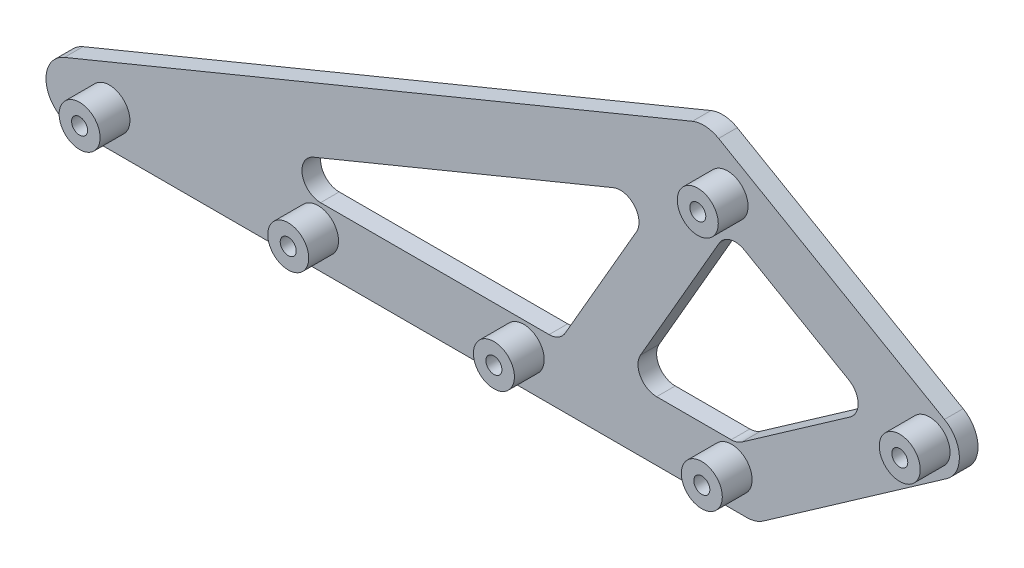
from build123d import *

# Parameters (mm, degrees)
BOSS_EXTRUDE1_DEPTH = 5
BOSS_EXTRUDE2_DEPTH = 5
FILLET1_R           = 5
SKETCH3_R           = 5.5
SKETCH3_R_2         = 2.15
BOSS_EXTRUDE3_DEPTH = 8
SKETCH4_R           = 2.15
CUT_EXTRUDE1_DEPTH  = 6


with BuildPart() as part:
    # Sketch1 → Boss-Extrude1 (new body)
    with BuildSketch(Plane.XY):
        with BuildLine():
            Line((0, 8), (180, 8))
            ThreePointArc((180, 8), (188, 0), (180, -8))
            Line((180, -8), (0, -8))
            ThreePointArc((0, -8), (-8, 0), (0, 8))
        make_face()
        with BuildLine():
            Line((175.411388509, 6.553216354), (224.560511167, 40.967802535))
            ThreePointArc((224.560511167, 40.967802535), (235.702339012, 39.003197672), (233.737734148, 27.861369827))
            Line((233.737734148, 27.861369827), (184.588611491, -6.553216354))
            ThreePointArc((184.588611491, -6.553216354), (173.446783646, -4.588611491), (175.411388509, 6.553216354))
        make_face()
        with BuildLine():
            Line((225.149122657, 27.486382951), (164.527344392, 62.486382951))
            ThreePointArc((164.527344392, 62.486382951), (161.599141162, 73.414586181), (172.527344392, 76.342789411))
            Line((172.527344392, 76.342789411), (233.149122657, 41.342789411))
            ThreePointArc((233.149122657, 41.342789411), (236.077325888, 30.414586181), (225.149122657, 27.486382951))
        make_face()
        with BuildLine():
            Line((-3.04678556, 7.397100632), (165.480558833, 76.811686813))
            ThreePointArc((165.480558833, 76.811686813), (175.924445024, 72.461371741), (171.574129952, 62.017485549))
            Line((171.574129952, 62.017485549), (3.04678556, -7.397100632))
            ThreePointArc((3.04678556, -7.397100632), (-7.397100632, -3.04678556), (-3.04678556, 7.397100632))
        make_face()
    extrude(amount=BOSS_EXTRUDE1_DEPTH)

    # Sketch2 → Boss-Extrude2 (add)
    with BuildSketch(Plane.XY.offset(5)):
        Polygon((147.229345289, 8), (175.147140962, 56.355040542), (167.935409097, 60.518735876), (157.826632887, 56.355040542), (129.908837213, 8), align=None)
    extrude(amount=-BOSS_EXTRUDE2_DEPTH)

    # Fillet1
    fillet1_edges = [part.edges().sort_by_distance(p)[0] for p in [
        (40.428445864, 8, 2.5),
        (177.477609689, 8, 2.5),
        (214.274021971, 33.765125259, 2.5),
        (157.826632887, 56.355040542, 2.5),
        (129.908837213, 8, 2.5),
        (147.229345289, 8, 2.5),
        (175.147140962, 56.355040542, 2.5),
    ]]
    fillet(fillet1_edges, radius=FILLET1_R)

    # Sketch3 → Boss-Extrude3 (add)
    with BuildSketch(Plane.XY.offset(5)):
        with Locations((174.937796577, 64.5)):
            Circle(SKETCH3_R)
        with Locations((174.937796577, 64.5)):
            Circle(SKETCH3_R_2, mode=Mode.SUBTRACT)
        with Locations((229.149122657, 34.414586181)):
            Circle(SKETCH3_R)
        with Locations((229.149122657, 34.414586181)):
            Circle(SKETCH3_R_2, mode=Mode.SUBTRACT)
        with Locations((176.018340463, 1.5)):
            Circle(SKETCH3_R)
        with Locations((176.018340463, 1.5)):
            Circle(SKETCH3_R_2, mode=Mode.SUBTRACT)
        with Locations((120.218340463, 1.5)):
            Circle(SKETCH3_R)
        with Locations((120.218340463, 1.5)):
            Circle(SKETCH3_R_2, mode=Mode.SUBTRACT)
        with Locations((65.018340463, 1.5)):
            Circle(SKETCH3_R)
        with Locations((65.018340463, 1.5)):
            Circle(SKETCH3_R_2, mode=Mode.SUBTRACT)
        with Locations((9.018340463, 1.5)):
            Circle(SKETCH3_R)
        with Locations((9.018340463, 1.5)):
            Circle(SKETCH3_R_2, mode=Mode.SUBTRACT)
    extrude(amount=BOSS_EXTRUDE3_DEPTH)

    # Sketch4 → Cut-Extrude1 (cut, through all)
    with BuildSketch(Plane.XY.offset(5)):
        with Locations((9.018340463, 1.5)):
            Circle(SKETCH4_R)
        with Locations((65.018340463, 1.5)):
            Circle(SKETCH4_R)
        with Locations((120.218340463, 1.5)):
            Circle(SKETCH4_R)
        with Locations((176.018340463, 1.5)):
            Circle(SKETCH4_R)
        with Locations((229.149122657, 34.414586181)):
            Circle(SKETCH4_R)
        with Locations((174.937796577, 64.5)):
            Circle(SKETCH4_R)
    extrude(amount=-CUT_EXTRUDE1_DEPTH, mode=Mode.SUBTRACT)


solid = part.part
